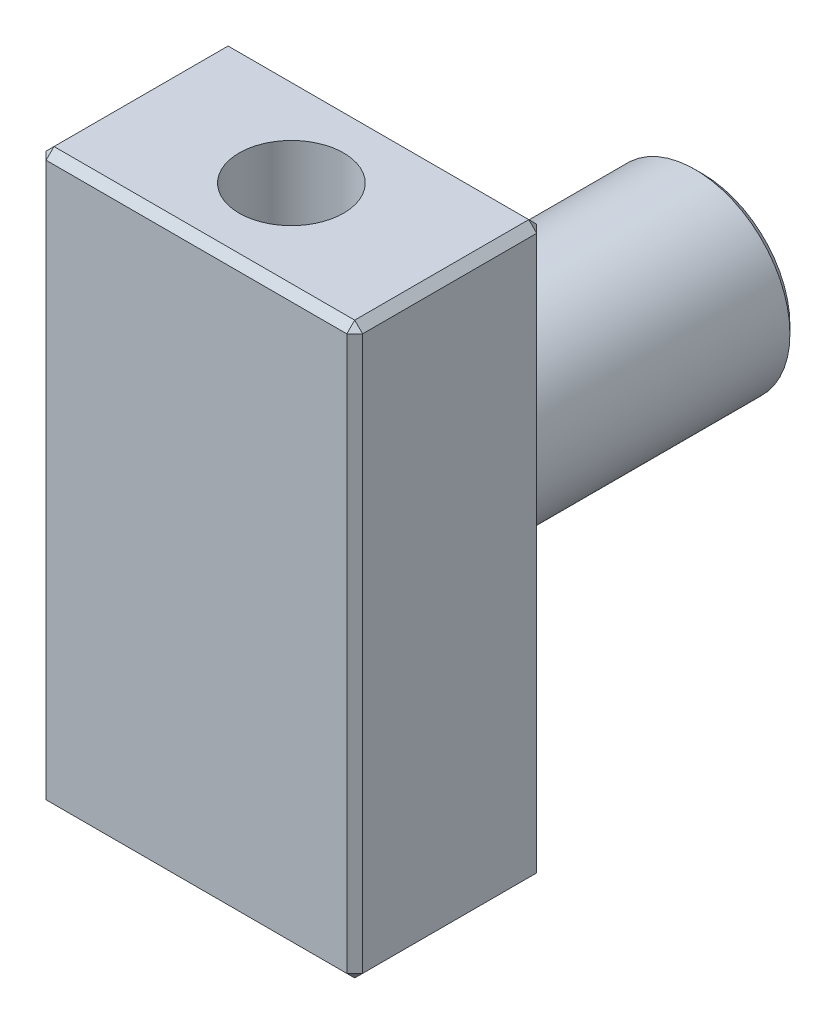
from build123d import *

# Parameters (mm, degrees)
SKETCH1_W                           = 10
SKETCH1_H                           = 18
EXTRUDE1_DEPTH                      = 6
SKETCH2_R                           = 3
EXTRUDE2_DEPTH                      = 10
M4X0_7_TAPPED_HOLE1_D               = 3.3
M4X0_7_TAPPED_HOLE1_DEPTH           = 8
M4X0_7_TAPPED_HOLE1_TIP             = 0.991420021
M4X0_7_TAPPED_HOLE1_ON_FACE_2_D     = 3.3
M4X0_7_TAPPED_HOLE1_ON_FACE_2_DEPTH = 8
M4X0_7_TAPPED_HOLE1_ON_FACE_2_TIP   = 0.991420021
CHAMFER3_SIZE                       = 0.25


with BuildPart() as part:
    # Sketch1 → Extrude1 (new body)
    with BuildSketch(Plane.XY):
        Rectangle(SKETCH1_W, SKETCH1_H)
    extrude(amount=EXTRUDE1_DEPTH)

    # Sketch2 → Extrude2 (add)
    with BuildSketch(Plane(origin=(0, 0, 0), x_dir=(-1, 0, 0), z_dir=(0, 0, -1))):
        with Locations(Location((0, 0, 0), (0, 0, 180))):  # turned: the seam where the file's is
            Circle(SKETCH2_R)
    extrude(amount=EXTRUDE2_DEPTH)

    # M4x0.7 Tapped Hole1
    with Locations(Plane(origin=(0, -9, 3), x_dir=(0, 0, -1), z_dir=(0, -1, 0))):
        with Locations((0, 0)):
            Hole(M4X0_7_TAPPED_HOLE1_D / 2, depth=M4X0_7_TAPPED_HOLE1_DEPTH)
            with Locations((0, 0, -(M4X0_7_TAPPED_HOLE1_DEPTH + M4X0_7_TAPPED_HOLE1_TIP / 2))):  # 118° drill point
                Cone(0, M4X0_7_TAPPED_HOLE1_D / 2, M4X0_7_TAPPED_HOLE1_TIP, mode=Mode.SUBTRACT)

    # M4x0.7 Tapped Hole1 on face 2
    with Locations(Plane(origin=(0, 9, 3), x_dir=(0, 0, 1), z_dir=(0, 1, 0))):
        with Locations((0, 0)):
            Hole(M4X0_7_TAPPED_HOLE1_ON_FACE_2_D / 2, depth=M4X0_7_TAPPED_HOLE1_ON_FACE_2_DEPTH)
            with Locations((0, 0, -(M4X0_7_TAPPED_HOLE1_ON_FACE_2_DEPTH + M4X0_7_TAPPED_HOLE1_ON_FACE_2_TIP / 2))):  # 118° drill point
                Cone(0, M4X0_7_TAPPED_HOLE1_ON_FACE_2_D / 2, M4X0_7_TAPPED_HOLE1_ON_FACE_2_TIP, mode=Mode.SUBTRACT)

    # Chamfer3
    chamfer3_edges = [part.edges().sort_by_distance(p)[0] for p in [
        (5, 0, 6),
        (-3, 0, 0),
        (0, 9, 6),
        (-3, 0, -10),
        (-5, 0, 6),
        (0, 9, 0),
        (5, 0, 0),
        (0, -9, 0),
        (-5, 0, 0),
        (0, -9, 6),
        (-5, 9, 3),
        (5, 9, 3),
        (5, -9, 3),
        (-5, -9, 3),
    ]]
    chamfer(chamfer3_edges, length=CHAMFER3_SIZE)


solid = part.part
